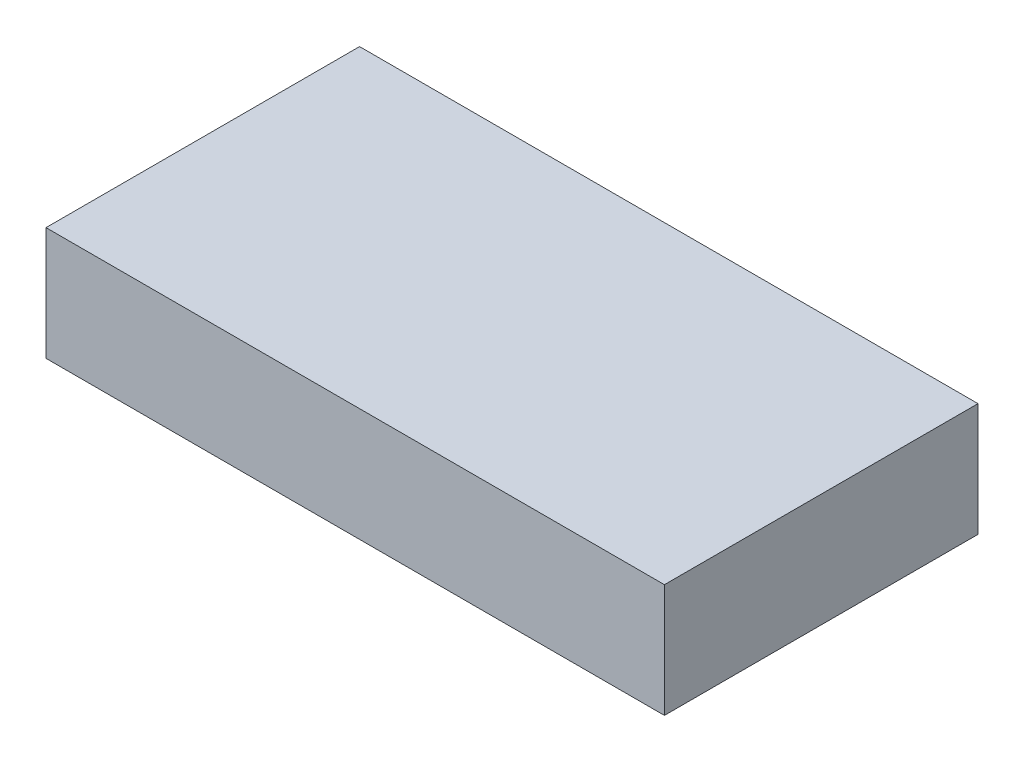
from build123d import *

# Parameters (mm, degrees)
SKETCH1_W           = 71
SKETCH1_H           = 36
BOSS_EXTRUDE1_DEPTH = 6.5


with BuildPart() as part:
    # Sketch1 → Boss-Extrude1 (new body, symmetric)
    with BuildSketch(Plane(origin=(0, 0, 0), x_dir=(1, 0, 0), z_dir=(0, 1, 0))):
        Rectangle(SKETCH1_W, SKETCH1_H)
    extrude(amount=BOSS_EXTRUDE1_DEPTH, both=True)


solid = part.part
